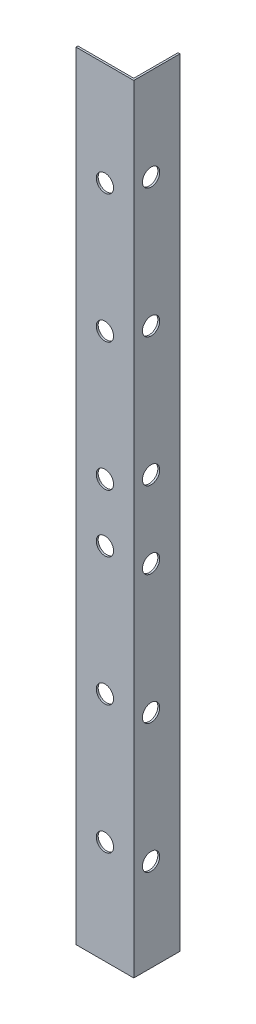
from build123d import *

# Parameters (mm, degrees)
BOSS_EXTRUDE1_DEPTH = 202
CUT_EXTRUDE1_REACH  = 14
SKETCH2_R           = 2.25
CUT_EXTRUDE2_REACH  = 17
SKETCH3_R           = 2.25


with BuildPart() as part:
    # Sketch1 → Boss-Extrude1 (new body)
    with BuildSketch(Plane(origin=(0, 0, 0), x_dir=(1, 0, 0), z_dir=(0, 1, 0))):
        Polygon((0, 0), (15, 0), (15, 12), (14.5, 12), (14.5, 0.5), (0, 0.5), align=None)
    extrude(amount=BOSS_EXTRUDE1_DEPTH)

    # Sketch2 → Cut-Extrude1 (cut, up to next)
    with BuildSketch(Plane.XY, mode=Mode.PRIVATE) as cut_extrude1_sk1:
        with Locations((7.5, 175.166666667)):
            Circle(SKETCH2_R)
    cut_extrude1_tool1 = extrude(cut_extrude1_sk1.sketch, amount=-CUT_EXTRUDE1_REACH, mode=Mode.PRIVATE) & part.part
    add(cut_extrude1_tool1.solids().sort_by_distance((7.5, 175.166667, 0))[0], mode=Mode.SUBTRACT)
    # Sketch2 → Cut-Extrude1 (cut, up to next)
    with BuildSketch(Plane.XY, mode=Mode.PRIVATE) as cut_extrude1_sk2:
        with Locations((7.5, 141.833333333)):
            Circle(SKETCH2_R)
    cut_extrude1_tool2 = extrude(cut_extrude1_sk2.sketch, amount=-CUT_EXTRUDE1_REACH, mode=Mode.PRIVATE) & part.part
    add(cut_extrude1_tool2.solids().sort_by_distance((7.5, 141.833333, 0))[0], mode=Mode.SUBTRACT)
    # Sketch2 → Cut-Extrude1 (cut, up to next)
    with BuildSketch(Plane.XY, mode=Mode.PRIVATE) as cut_extrude1_sk3:
        with Locations((7.5, 108.5)):
            Circle(SKETCH2_R)
    cut_extrude1_tool3 = extrude(cut_extrude1_sk3.sketch, amount=-CUT_EXTRUDE1_REACH, mode=Mode.PRIVATE) & part.part
    add(cut_extrude1_tool3.solids().sort_by_distance((7.5, 108.5, 0))[0], mode=Mode.SUBTRACT)
    # Sketch2 → Cut-Extrude1 (cut, up to next)
    with BuildSketch(Plane.XY, mode=Mode.PRIVATE) as cut_extrude1_sk4:
        with Locations((7.5, 93.5)):
            Circle(SKETCH2_R)
    cut_extrude1_tool4 = extrude(cut_extrude1_sk4.sketch, amount=-CUT_EXTRUDE1_REACH, mode=Mode.PRIVATE) & part.part
    add(cut_extrude1_tool4.solids().sort_by_distance((7.5, 93.5, 0))[0], mode=Mode.SUBTRACT)
    # Sketch2 → Cut-Extrude1 (cut, up to next)
    with BuildSketch(Plane.XY, mode=Mode.PRIVATE) as cut_extrude1_sk5:
        with Locations((7.5, 60.166666667)):
            Circle(SKETCH2_R)
    cut_extrude1_tool5 = extrude(cut_extrude1_sk5.sketch, amount=-CUT_EXTRUDE1_REACH, mode=Mode.PRIVATE) & part.part
    add(cut_extrude1_tool5.solids().sort_by_distance((7.5, 60.166667, 0))[0], mode=Mode.SUBTRACT)
    # Sketch2 → Cut-Extrude1 (cut, up to next)
    with BuildSketch(Plane.XY, mode=Mode.PRIVATE) as cut_extrude1_sk6:
        with Locations((7.5, 26.833333333)):
            Circle(SKETCH2_R)
    cut_extrude1_tool6 = extrude(cut_extrude1_sk6.sketch, amount=-CUT_EXTRUDE1_REACH, mode=Mode.PRIVATE) & part.part
    add(cut_extrude1_tool6.solids().sort_by_distance((7.5, 26.833333, 0))[0], mode=Mode.SUBTRACT)

    # Sketch3 → Cut-Extrude2 (cut, up to next)
    with BuildSketch(Plane(origin=(15, 0, 0), x_dir=(0, 0, -1), z_dir=(1, 0, 0)), mode=Mode.PRIVATE) as cut_extrude2_sk1:
        with Locations((4.5, 24)):
            Circle(SKETCH3_R)
    cut_extrude2_tool1 = extrude(cut_extrude2_sk1.sketch, amount=-CUT_EXTRUDE2_REACH, mode=Mode.PRIVATE) & part.part
    add(cut_extrude2_tool1.solids().sort_by_distance((15, 24, -4.5))[0], mode=Mode.SUBTRACT)
    # Sketch3 → Cut-Extrude2 (cut, up to next)
    with BuildSketch(Plane(origin=(15, 0, 0), x_dir=(0, 0, -1), z_dir=(1, 0, 0)), mode=Mode.PRIVATE) as cut_extrude2_sk2:
        with Locations((4.5, 57.5)):
            Circle(SKETCH3_R)
    cut_extrude2_tool2 = extrude(cut_extrude2_sk2.sketch, amount=-CUT_EXTRUDE2_REACH, mode=Mode.PRIVATE) & part.part
    add(cut_extrude2_tool2.solids().sort_by_distance((15, 57.5, -4.5))[0], mode=Mode.SUBTRACT)
    # Sketch3 → Cut-Extrude2 (cut, up to next)
    with BuildSketch(Plane(origin=(15, 0, 0), x_dir=(0, 0, -1), z_dir=(1, 0, 0)), mode=Mode.PRIVATE) as cut_extrude2_sk3:
        with Locations((4.5, 91)):
            Circle(SKETCH3_R)
    cut_extrude2_tool3 = extrude(cut_extrude2_sk3.sketch, amount=-CUT_EXTRUDE2_REACH, mode=Mode.PRIVATE) & part.part
    add(cut_extrude2_tool3.solids().sort_by_distance((15, 91, -4.5))[0], mode=Mode.SUBTRACT)
    # Sketch3 → Cut-Extrude2 (cut, up to next)
    with BuildSketch(Plane(origin=(15, 0, 0), x_dir=(0, 0, -1), z_dir=(1, 0, 0)), mode=Mode.PRIVATE) as cut_extrude2_sk4:
        with Locations((4.5, 111)):
            Circle(SKETCH3_R)
    cut_extrude2_tool4 = extrude(cut_extrude2_sk4.sketch, amount=-CUT_EXTRUDE2_REACH, mode=Mode.PRIVATE) & part.part
    add(cut_extrude2_tool4.solids().sort_by_distance((15, 111, -4.5))[0], mode=Mode.SUBTRACT)
    # Sketch3 → Cut-Extrude2 (cut, up to next)
    with BuildSketch(Plane(origin=(15, 0, 0), x_dir=(0, 0, -1), z_dir=(1, 0, 0)), mode=Mode.PRIVATE) as cut_extrude2_sk5:
        with Locations((4.5, 144.5)):
            Circle(SKETCH3_R)
    cut_extrude2_tool5 = extrude(cut_extrude2_sk5.sketch, amount=-CUT_EXTRUDE2_REACH, mode=Mode.PRIVATE) & part.part
    add(cut_extrude2_tool5.solids().sort_by_distance((15, 144.5, -4.5))[0], mode=Mode.SUBTRACT)
    # Sketch3 → Cut-Extrude2 (cut, up to next)
    with BuildSketch(Plane(origin=(15, 0, 0), x_dir=(0, 0, -1), z_dir=(1, 0, 0)), mode=Mode.PRIVATE) as cut_extrude2_sk6:
        with Locations((4.5, 178)):
            Circle(SKETCH3_R)
    cut_extrude2_tool6 = extrude(cut_extrude2_sk6.sketch, amount=-CUT_EXTRUDE2_REACH, mode=Mode.PRIVATE) & part.part
    add(cut_extrude2_tool6.solids().sort_by_distance((15, 178, -4.5))[0], mode=Mode.SUBTRACT)


solid = part.part
